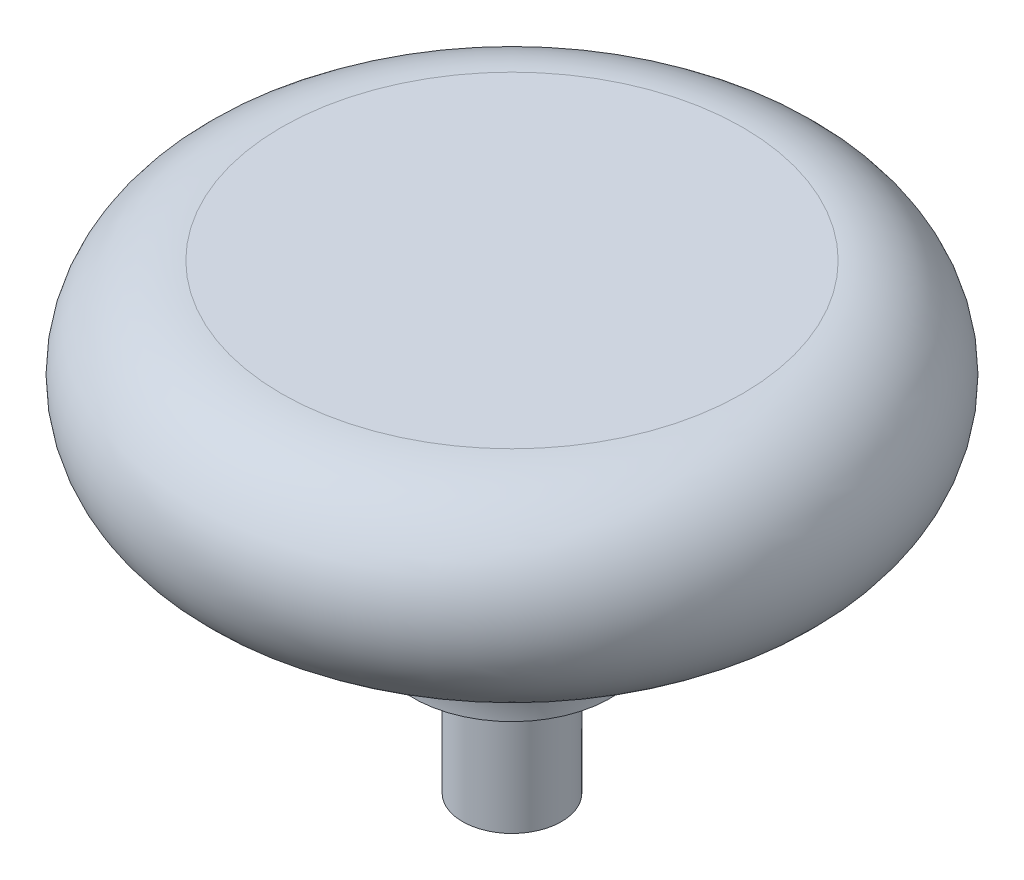
from build123d import *


with BuildPart() as part:
    # Sketch1 → Base-Revolve (revolve)
    with BuildSketch(Plane.XY, mode=Mode.PRIVATE) as base_revolve_sk:
        with BuildLine():
            Line((0, 0), (0, 22.225))
            Line((0, 22.225), (11.1125, 22.225))
            ThreePointArc((11.1125, 22.225), (15.875, 17.4625), (11.1125, 12.7))
            ThreePointArc((11.1125, 12.7), (6.622371939, 10.840128061), (4.7625, 6.35))
            Line((4.7625, 6.35), (2.38125, 6.35))
            Line((2.38125, 6.35), (2.38125, 0))
            Line((2.38125, 0), (0, 0))
        make_face()
    revolve(base_revolve_sk.sketch.rotate(Axis((0, 0, 0), (0, 1, 0)), 90), axis=Axis((0, 0, 0), (0, 1, 0)))  # turned: the seam where the file's is


solid = part.part
